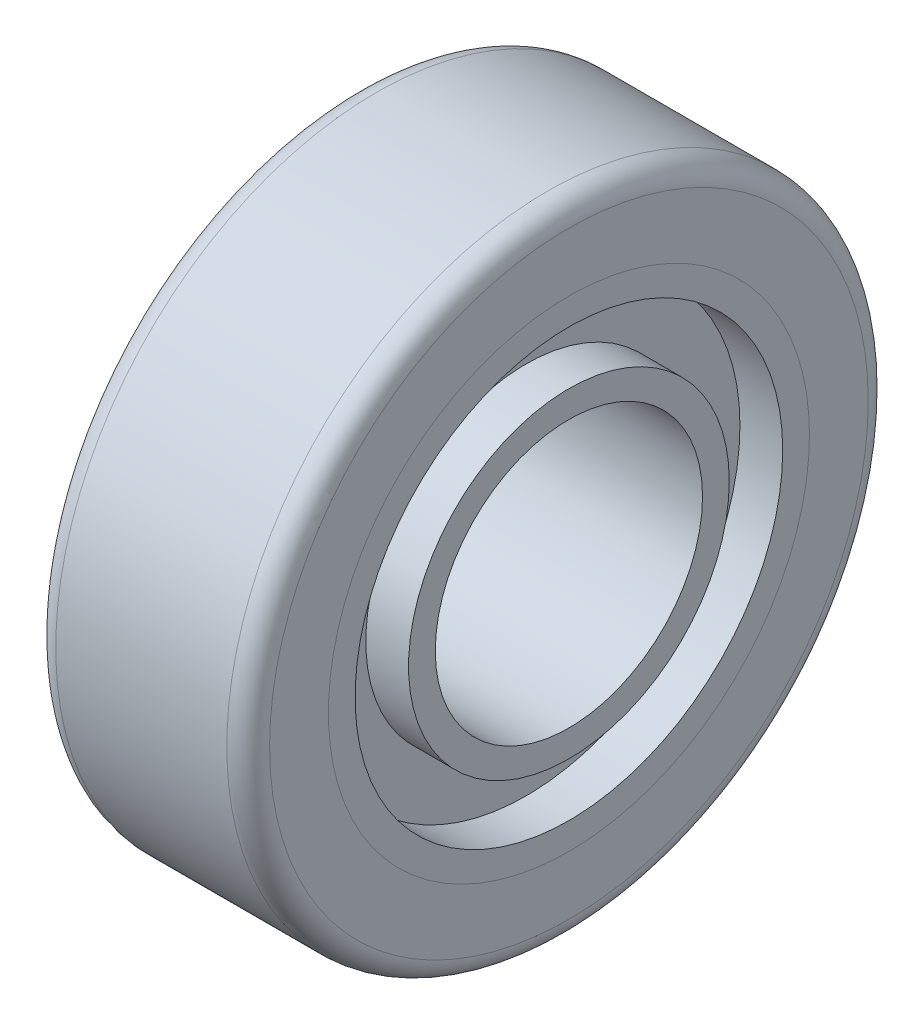
from build123d import *

# Parameters (mm, degrees)
SKETCH1_R           = 38.1
BOSS_EXTRUDE1_DEPTH = 25.4
FILLET2_R           = 2.54
SKETCH2_R           = 28.575
CUT_EXTRUDE1_DEPTH  = 25.4
SKETCH3_R           = 28.575
BOSS_EXTRUDE3_DEPTH = 25.4
SKETCH7_R           = 25.4
SKETCH7_R_2         = 19.05
CUT_EXTRUDE3_DEPTH  = 5.08
SKETCH8_R           = 15.875
CUT_EXTRUDE4_DEPTH  = 25.4


with BuildPart() as part:
    # Sketch1 → Boss-Extrude1 (new body)
    with BuildSketch(Plane(origin=(0, 0, 0), x_dir=(0, 0, -1), z_dir=(1, 0, 0))):
        Circle(SKETCH1_R)
    extrude(amount=BOSS_EXTRUDE1_DEPTH)

    # Fillet2
    fillet2_edges = [part.edges().sort_by_distance(p)[0] for p in [
        (0, 0, 38.1),
        (25.4, 0, 38.1),
    ]]
    fillet(fillet2_edges, radius=FILLET2_R)

    # Sketch2 → Cut-Extrude1 (cut)
    with BuildSketch(Plane(origin=(25.4, 0, 0), x_dir=(0, 0, -1), z_dir=(1, 0, 0))):
        Circle(SKETCH2_R)
    extrude(amount=-CUT_EXTRUDE1_DEPTH, mode=Mode.SUBTRACT)


with BuildPart() as body_2:
    # Sketch3 → Boss-Extrude3 (new body)
    with BuildSketch(Plane(origin=(25.4, 0, 0), x_dir=(0, 0, -1), z_dir=(1, 0, 0))):
        Circle(SKETCH3_R)
    extrude(amount=-BOSS_EXTRUDE3_DEPTH)

    # Sketch7 → Cut-Extrude3 (cut)
    with BuildSketch(Plane(origin=(25.4, 0, 0), x_dir=(0, 0, -1), z_dir=(1, 0, 0))):
        Circle(SKETCH7_R)
        Circle(SKETCH7_R_2, mode=Mode.SUBTRACT)
    cut_extrude3 = extrude(amount=-CUT_EXTRUDE3_DEPTH, mode=Mode.SUBTRACT)

    # Sketch8 → Cut-Extrude4 (cut)
    with BuildSketch(Plane(origin=(25.4, 0, 0), x_dir=(0, 0, -1), z_dir=(1, 0, 0))):
        Circle(SKETCH8_R)
    extrude(amount=-CUT_EXTRUDE4_DEPTH, mode=Mode.SUBTRACT)

    # Mirror1: Cut-Extrude3 across plane
    add(cut_extrude3.mirror(Plane.ZY.offset(-12.7)), mode=Mode.SUBTRACT)


solid = Compound([part.part, body_2.part])
